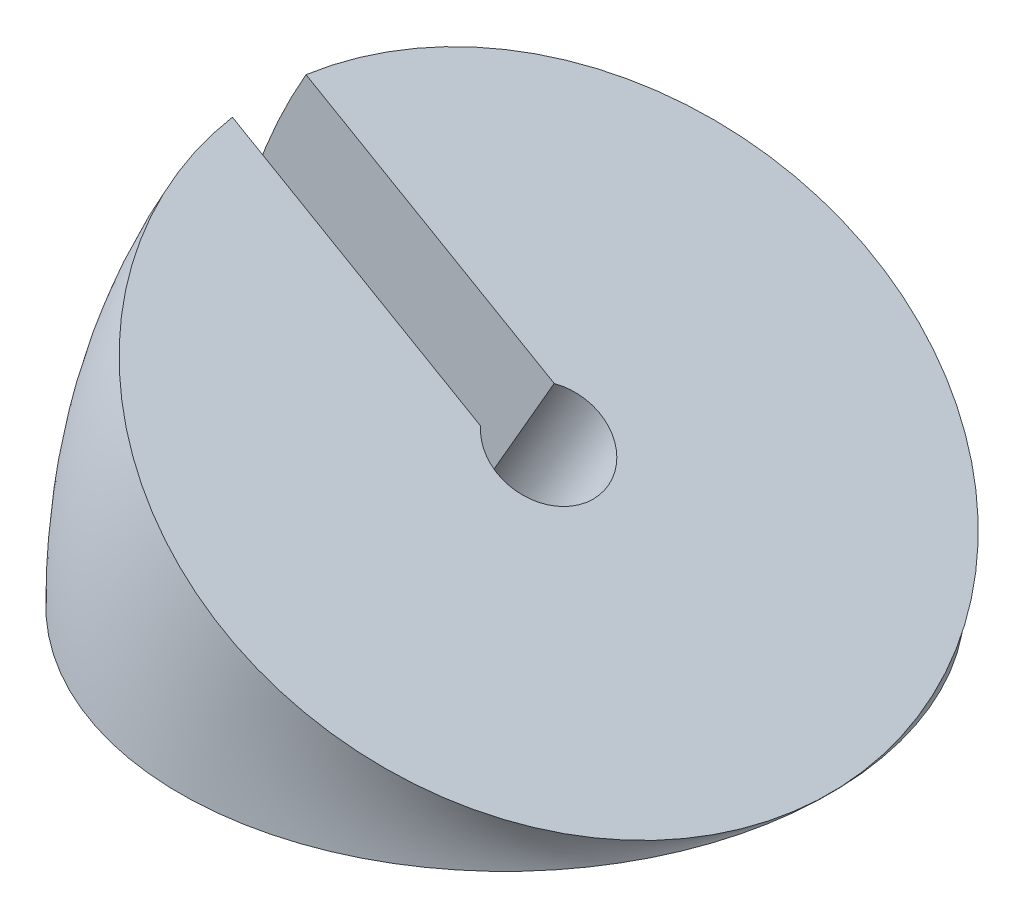
from build123d import *

# Parameters (mm, degrees)
SKETCH_1_R               = 22.05
REVOLVE_8_ANGLE          = 30
SKETCH_3_R               = 3.5
SKETCH_3_W               = 30
SKETCH_3_H               = 5
CUT_EXTRUDE_1_DEPTH      = 20.095860153
CUT_EXTRUDE_1_DEPTH_BACK = 23.07500005


with BuildPart() as part:
    # 스케치1 → 회전8 (revolve)
    with BuildSketch(Plane(origin=(0, 0, 0), x_dir=(1, 0, 0), z_dir=(0, 1, 0))):
        Circle(SKETCH_1_R)
    revolve(axis=Axis((22.1, 0, -22.238779178), (0, 0, -1)), revolution_arc=REVOLVE_8_ANGLE)

    # 스케치3 → 컷-돌출1 (cut, two sides)
    with BuildSketch(Plane(origin=(5.525, 9.569580712, 0), x_dir=(0.866025404, -0.5, 0), z_dir=(0.5, 0.866025404, 0))) as cut_extrude_1_sk:
        with Locations((-2.960838576, 0)):
            Circle(SKETCH_3_R)
        with Locations((-17.960838576, 0)):
            Rectangle(SKETCH_3_W, SKETCH_3_H)
    extrude(amount=CUT_EXTRUDE_1_DEPTH, mode=Mode.SUBTRACT)
    extrude(cut_extrude_1_sk.sketch, amount=-CUT_EXTRUDE_1_DEPTH_BACK, mode=Mode.SUBTRACT)


solid = part.part
